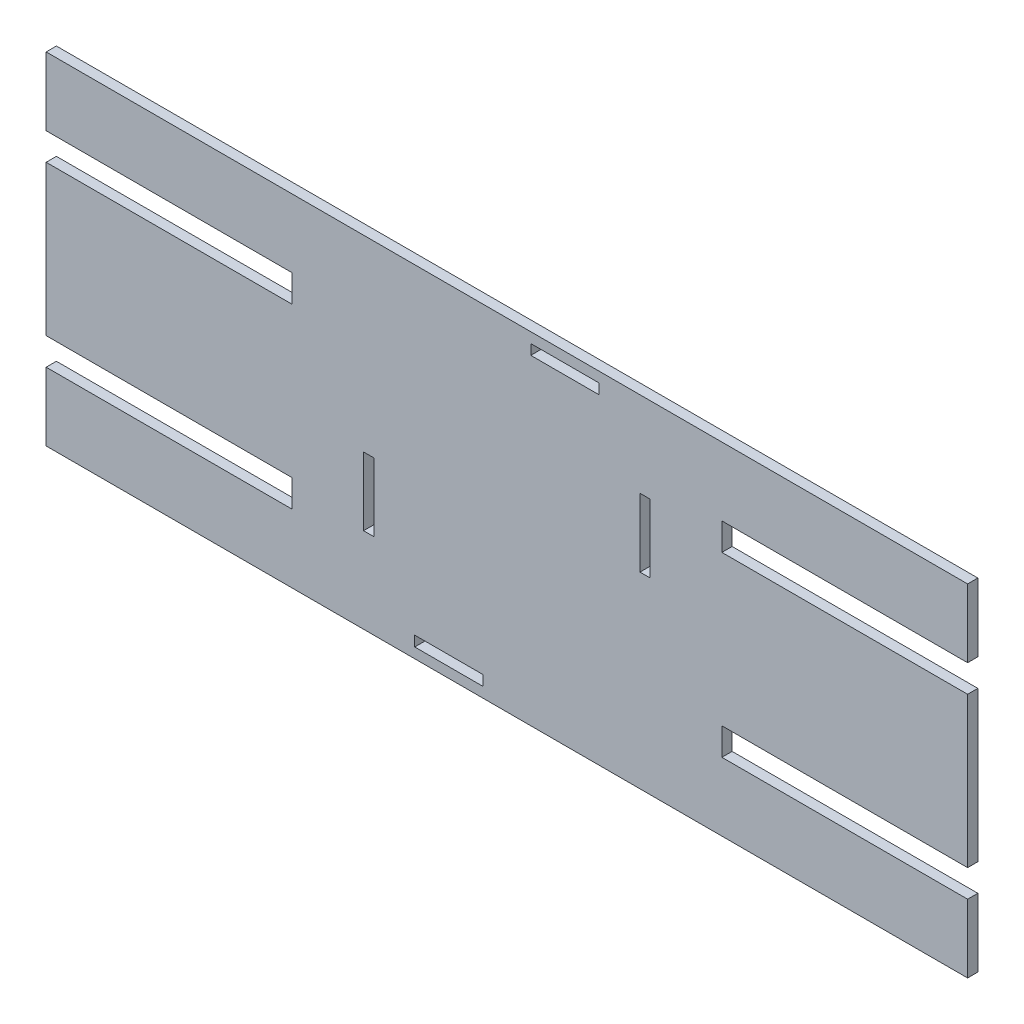
from build123d import *

# Parameters (mm, degrees)
SKETCH_1_W      = 20
SKETCH_1_H      = 3
SKETCH_1_W_2    = 3
SKETCH_1_H_2    = 20
EXTRUDE_1_DEPTH = 3


with BuildPart() as part:
    # Эскиз1 → Бобышка-Вытянуть1 (new body)
    with BuildSketch(Plane.XY):
        Polygon((0, 0), (90, 0), (180, 0), (180, 20), (108, 20), (108, 28), (180, 28), (180, 72), (108, 72), (108, 80), (180, 80), (180, 100), (90, 100), (0, 100), (-90, 100), (-90, 80), (-18, 80), (-18, 72), (-90, 72), (-90, 28), (-18, 28), (-18, 20), (-90, 20), (-90, 0), align=None)
        with Locations((28, 4.5)):
            Rectangle(SKETCH_1_W, SKETCH_1_H, mode=Mode.SUBTRACT)
        with Locations((62, 95.5)):
            Rectangle(SKETCH_1_W, SKETCH_1_H, mode=Mode.SUBTRACT)
        with Locations((4.5, 35)):
            Rectangle(SKETCH_1_W_2, SKETCH_1_H_2, mode=Mode.SUBTRACT)
        with Locations((85.5, 65)):
            Rectangle(SKETCH_1_W_2, SKETCH_1_H_2, mode=Mode.SUBTRACT)
    extrude(amount=EXTRUDE_1_DEPTH)


solid = part.part
